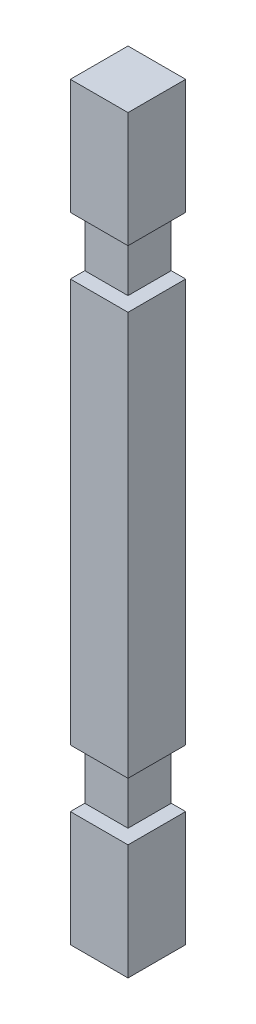
from build123d import *

# Parameters (mm, degrees)
SKETCH2_W           = 50.8
SKETCH2_H           = 660.4
BOSS_EXTRUDE1_DEPTH = 50.8
SKETCH5_W           = 50.8
SKETCH5_H           = 50.8
CUT_EXTRUDE1_DEPTH  = 12.7
SKETCH6_W           = 50.8
SKETCH6_H           = 50.8
CUT_EXTRUDE2_DEPTH  = 12.7
SKETCH10_W          = 50.8
SKETCH10_H          = 50.8
CUT_EXTRUDE3_DEPTH  = 12.7
SKETCH11_W          = 50.8
SKETCH11_H          = 50.8
CUT_EXTRUDE4_DEPTH  = 12.7
SKETCH12_R          = 8
CUT_EXTRUDE5_DEPTH  = 16
SKETCH13_R          = 8
CUT_EXTRUDE6_DEPTH  = 16
SKETCH14_R          = 8
CUT_EXTRUDE7_DEPTH  = 16
SKETCH15_R          = 8
CUT_EXTRUDE8_DEPTH  = 16


with BuildPart() as part:
    # Sketch2 → Boss-Extrude1 (new body)
    with BuildSketch(Plane.XY):
        Rectangle(SKETCH2_W, SKETCH2_H)
    extrude(amount=BOSS_EXTRUDE1_DEPTH)

    # Sketch5 → Cut-Extrude1 (cut)
    with BuildSketch(Plane.XY.offset(50.8)):
        with Locations((0, 203.2)):
            Rectangle(SKETCH5_W, SKETCH5_H)
    extrude(amount=-CUT_EXTRUDE1_DEPTH, mode=Mode.SUBTRACT)

    # Sketch6 → Cut-Extrude2 (cut)
    with BuildSketch(Plane(origin=(25.4, 0, 0), x_dir=(0, 0, -1), z_dir=(1, 0, 0))):
        with Locations((-25.4, 203.2)):
            Rectangle(SKETCH6_W, SKETCH6_H)
    extrude(amount=-CUT_EXTRUDE2_DEPTH, mode=Mode.SUBTRACT)

    # Sketch10 → Cut-Extrude3 (cut)
    with BuildSketch(Plane.XY.offset(50.8)):
        with Locations((0, -203.2)):
            Rectangle(SKETCH10_W, SKETCH10_H)
    extrude(amount=-CUT_EXTRUDE3_DEPTH, mode=Mode.SUBTRACT)

    # Sketch11 → Cut-Extrude4 (cut)
    with BuildSketch(Plane(origin=(25.4, 0, 0), x_dir=(0, 0, -1), z_dir=(1, 0, 0))):
        with Locations((-25.4, -203.2)):
            Rectangle(SKETCH11_W, SKETCH11_H)
    extrude(amount=-CUT_EXTRUDE4_DEPTH, mode=Mode.SUBTRACT)

    # Sketch12 → Cut-Extrude5 (cut)
    with BuildSketch(Plane(origin=(0, 0, 0), x_dir=(-1, 0, 0), z_dir=(0, 0, -1))):
        with Locations((0, 304.8)):
            Circle(SKETCH12_R)
    extrude(amount=-CUT_EXTRUDE5_DEPTH, mode=Mode.SUBTRACT)

    # Sketch13 → Cut-Extrude6 (cut)
    with BuildSketch(Plane.ZY.offset(25.4)):
        with Locations((25.4, 304.8)):
            Circle(SKETCH13_R)
    extrude(amount=-CUT_EXTRUDE6_DEPTH, mode=Mode.SUBTRACT)

    # Sketch14 → Cut-Extrude7 (cut)
    with BuildSketch(Plane(origin=(0, 0, 0), x_dir=(-1, 0, 0), z_dir=(0, 0, -1))):
        with Locations((0, -304.8)):
            Circle(SKETCH14_R)
    extrude(amount=-CUT_EXTRUDE7_DEPTH, mode=Mode.SUBTRACT)

    # Sketch15 → Cut-Extrude8 (cut)
    with BuildSketch(Plane.ZY.offset(25.4)):
        with Locations((25.4, -304.8)):
            Circle(SKETCH15_R)
    extrude(amount=-CUT_EXTRUDE8_DEPTH, mode=Mode.SUBTRACT)


solid = part.part
